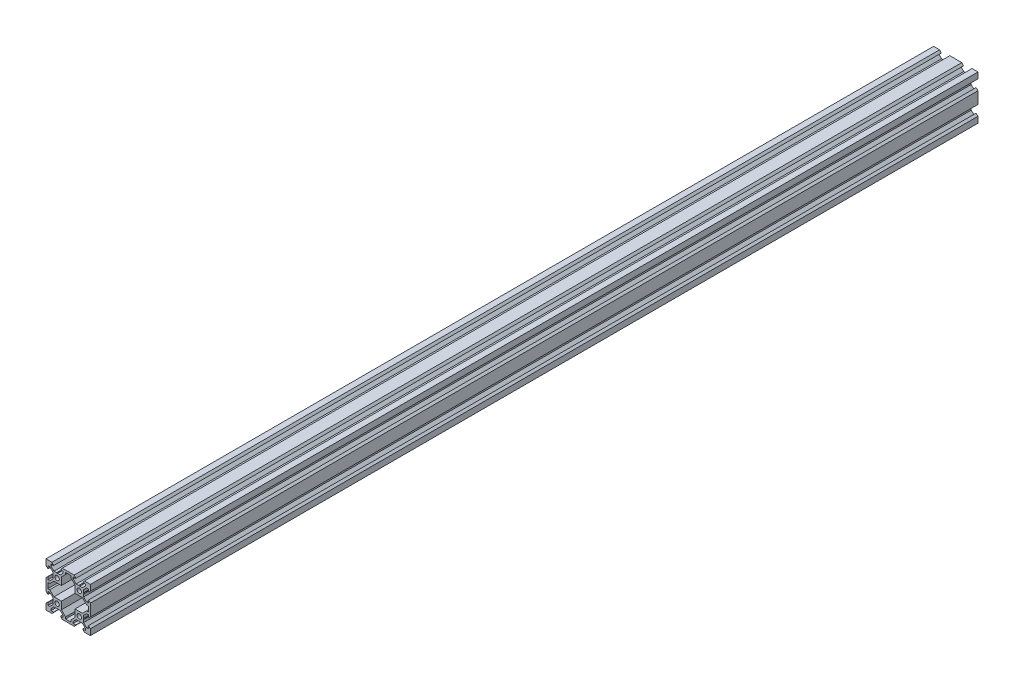
from build123d import *

# Parameters (mm, degrees)
SKETCH2_R           = 2
BOSS_EXTRUDE1_DEPTH = 800


with BuildPart() as part:
    # Sketch2 → Boss-Extrude1 (new body)
    with BuildSketch(Plane.XY):
        Polygon((-13.9, -12.839339828), (-13.9, -10.519615242), (-13.6, -10), (-13.9, -9.480384758), (-13.9, -7.160660172), (-16.56, -4.500660172), (-18.2, -4.500660172), (-18.2, -6.900379336), (-20, -5.39), (-20, 5.39), (-18.2, 6.900379336), (-18.2, 4.500660172), (-16.56, 4.500660172), (-13.9, 7.160660172), (-13.9, 9.480384758), (-13.6, 10), (-13.9, 10.519615242), (-13.9, 12.839339828), (-16.560660172, 15.5), (-18.2, 15.5), (-18.2, 13.099620664), (-20, 14.61), (-20, 20), (-14.61, 20), (-13.099620664, 18.2), (-15.5, 18.2), (-15.5, 16.560660172), (-12.839339828, 13.9), (-10.519615242, 13.9), (-10, 13.6), (-9.480384758, 13.9), (-7.160660172, 13.9), (-4.500660172, 16.56), (-4.500660172, 18.2), (-6.900379336, 18.2), (-5.39, 20), (5.39, 20), (6.900379336, 18.2), (4.500660172, 18.2), (4.500660172, 16.56), (7.160660172, 13.9), (9.480384758, 13.9), (10, 13.6), (10.519615242, 13.9), (12.839339828, 13.9), (15.5, 16.560660172), (15.5, 18.2), (13.099620664, 18.2), (14.61, 20), (20, 20), (20, 14.61), (18.2, 13.099620664), (18.2, 15.5), (16.560660172, 15.5), (13.9, 12.839339828), (13.9, 10.519615242), (13.6, 10), (13.9, 9.480384758), (13.9, 7.160660172), (16.56, 4.500660172), (18.2, 4.500660172), (18.2, 6.900379336), (20, 5.39), (20, -5.39), (18.2, -6.900379336), (18.2, -4.500660172), (16.56, -4.500660172), (13.9, -7.160660172), (13.9, -9.480384758), (13.6, -10), (13.9, -10.519615242), (13.9, -12.839339828), (16.560660172, -15.5), (18.2, -15.5), (18.2, -13.099620664), (20, -14.61), (20, -20), (14.61, -20), (13.099620664, -18.2), (15.5, -18.2), (15.5, -16.560660172), (12.839339828, -13.9), (10.519615242, -13.9), (10, -13.6), (9.480384758, -13.9), (7.160660172, -13.9), (4.500660172, -16.56), (4.500660172, -18.2), (6.900379336, -18.2), (5.39, -20), (-5.39, -20), (-6.900379336, -18.2), (-4.500660172, -18.2), (-4.500660172, -16.56), (-7.160660172, -13.9), (-9.480384758, -13.9), (-10, -13.6), (-10.519615242, -13.9), (-12.839339828, -13.9), (-15.5, -16.560660172), (-15.5, -18.2), (-13.099620664, -18.2), (-14.61, -20), (-20, -20), (-20, -14.61), (-18.2, -13.099620664), (-18.2, -15.5), (-16.560660172, -15.5), align=None)
        with Locations((-10, -10)):
            Circle(SKETCH2_R, mode=Mode.SUBTRACT)
        with Locations((10, -10)):
            Circle(SKETCH2_R, mode=Mode.SUBTRACT)
        with Locations((10, 10)):
            Circle(SKETCH2_R, mode=Mode.SUBTRACT)
        with Locations((-10, 10)):
            Circle(SKETCH2_R, mode=Mode.SUBTRACT)
        Polygon((-12.839339828, -6.1), (-6.1, -6.1), (-6.1, -12.839339828), (-2.379339828, -16.56), (-2.379339828, -18.2), (2.379339828, -18.2), (2.379339828, -16.56), (6.1, -12.839339828), (6.1, -6.1), (12.839339828, -6.1), (16.56, -2.379339828), (18.2, -2.379339828), (18.2, 2.379339828), (16.56, 2.379339828), (12.839339828, 6.1), (6.1, 6.1), (6.1, 12.839339828), (2.379339828, 16.56), (2.379339828, 18.2), (-2.379339828, 18.2), (-2.379339828, 16.56), (-6.1, 12.839339828), (-6.1, 6.1), (-12.839339828, 6.1), (-16.56, 2.379339828), (-18.2, 2.379339828), (-18.2, -2.379339828), (-16.56, -2.379339828), align=None, mode=Mode.SUBTRACT)
    extrude(amount=-BOSS_EXTRUDE1_DEPTH)


solid = part.part
